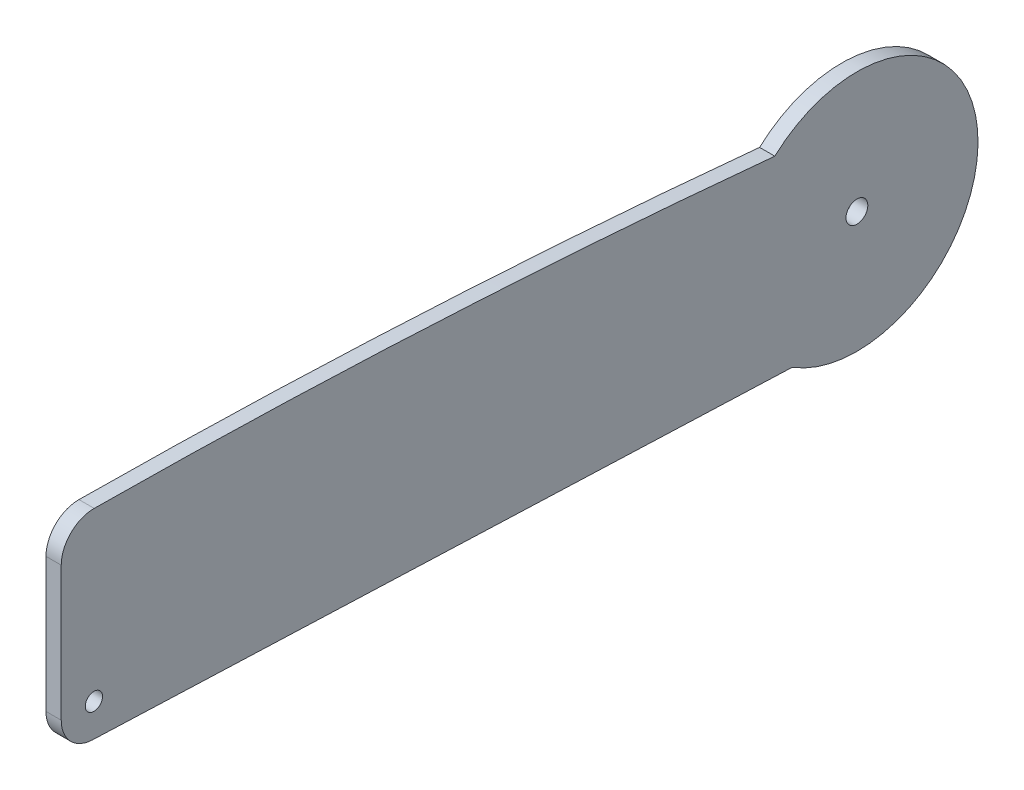
from build123d import *

# Parameters (mm, degrees)
SKETCH2_R           = 4
SKETCH2_R_2         = 3.175
BOSS_EXTRUDE1_DEPTH = 5.588


with BuildPart() as part:
    # Sketch2 → Boss-Extrude1 (new body)
    with BuildSketch(Plane(origin=(0, 0, 0), x_dir=(0, 0, -1), z_dir=(1, 0, 0))):
        with BuildLine():
            Line((-292, 33.638045694), (-292, -15.648345659))
            ThreePointArc((-292, -15.648345659), (-288.648466484, -23.967241468), (-280.46599542, -27.639294256))
            Line((-280.46599542, -27.639294256), (-23.677807257, -37.618664829))
            ThreePointArc((-23.677807257, -37.618664829), (44.264265693, 4.059221924), (-30.124927866, 32.684724583))
            ThreePointArc((-30.124927866, 32.684724583), (-154.873072642, 41.908750383), (-279.906177735, 45.637678913))
            ThreePointArc((-279.906177735, 45.637678913), (-288.452045102, 42.156433663), (-292, 33.638045694))
        make_face()
        Circle(SKETCH2_R, mode=Mode.SUBTRACT)
        with Locations((-280, -15.648345659)):
            Circle(SKETCH2_R_2, mode=Mode.SUBTRACT)
    extrude(amount=BOSS_EXTRUDE1_DEPTH)


solid = part.part
